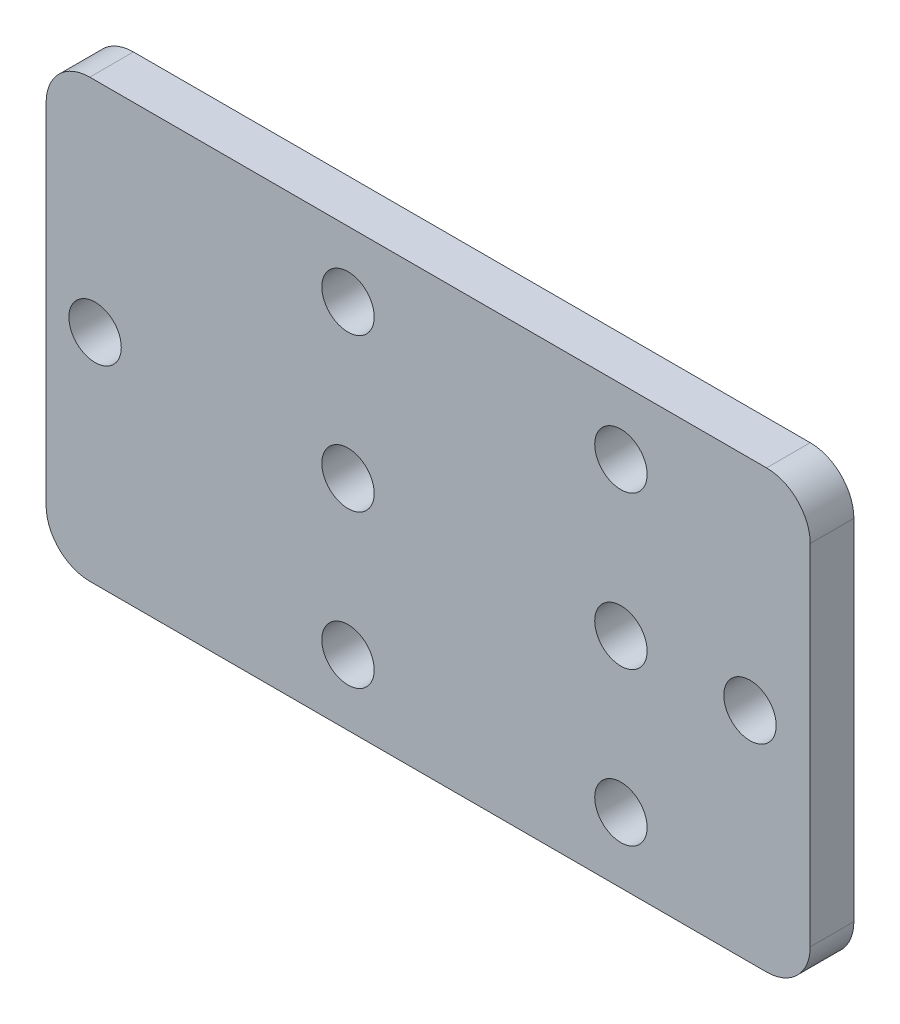
from build123d import *

# Parameters (mm, degrees)
SKETCH1_W           = 44.45
SKETCH1_H           = 25.4
SKETCH1_R           = 1.524
BOSS_EXTRUDE1_DEPTH = 2.54
FILLET1_R           = 2.54


with BuildPart() as part:
    # Sketch1 → Boss-Extrude1 (new body)
    with BuildSketch(Plane.XY):
        with Locations((17.145, -28.589614644)):
            Rectangle(SKETCH1_W, SKETCH1_H)
        with Locations((12.482257686, -28.589614644)):
            Circle(SKETCH1_R, mode=Mode.SUBTRACT)
        with Locations((28.357257686, -28.589614644)):
            Circle(SKETCH1_R, mode=Mode.SUBTRACT)
        with Locations((12.482257686, -19.699614644)):
            Circle(SKETCH1_R, mode=Mode.SUBTRACT)
        with Locations((28.357257686, -19.699614644)):
            Circle(SKETCH1_R, mode=Mode.SUBTRACT)
        with Locations((12.482257686, -37.479614644)):
            Circle(SKETCH1_R, mode=Mode.SUBTRACT)
        with Locations((28.357257686, -37.479614644)):
            Circle(SKETCH1_R, mode=Mode.SUBTRACT)
        with Locations((-2.231491516, -28.589614644)):
            Circle(SKETCH1_R, mode=Mode.SUBTRACT)
        with Locations((35.868508484, -28.589614644)):
            Circle(SKETCH1_R, mode=Mode.SUBTRACT)
    extrude(amount=BOSS_EXTRUDE1_DEPTH)

    # Fillet1
    fillet1_edges = [part.edges().sort_by_distance(p)[0] for p in [
        (-5.08, -15.889614644, 1.27),
        (39.37, -15.889614644, 1.27),
        (39.37, -41.289614644, 1.27),
        (-5.08, -41.289614644, 1.27),
    ]]
    fillet(fillet1_edges, radius=FILLET1_R)


solid = part.part
